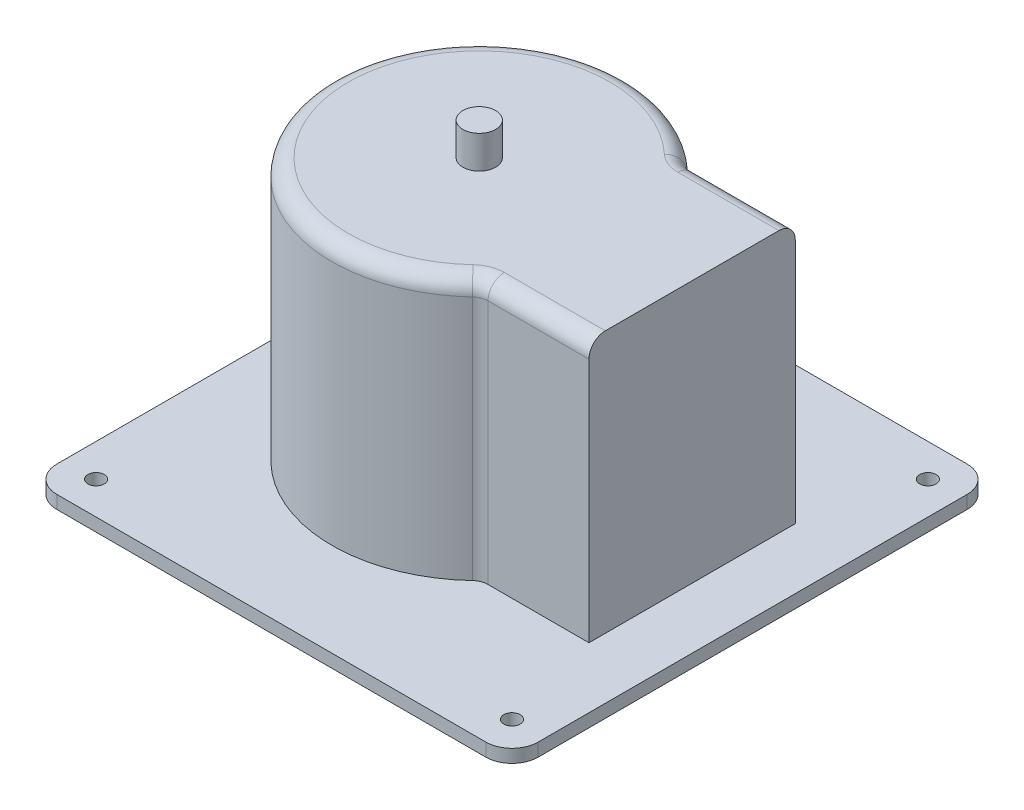
from build123d import *

# Parameters (mm, degrees)
SKETCH1_R           = 45
BOSS_EXTRUDE1_DEPTH = 80
BOSS_EXTRUDE2_REACH = 112
SKETCH2_W           = 63
SKETCH2_H           = 80
FILLET1_R           = 5
SKETCH3_R           = 5
BOSS_EXTRUDE3_DEPTH = 10
SKETCH4_W           = 147
SKETCH4_H           = 147
BOSS_EXTRUDE4_DEPTH = 4
SKETCH5_R           = 2.5
CUT_EXTRUDE1_DEPTH  = 5
FILLET2_R           = 8


with BuildPart() as part:
    # Sketch1 → Boss-Extrude1 (new body)
    with BuildSketch(Plane(origin=(0, 0, 0), x_dir=(1, 0, 0), z_dir=(0, 1, 0))):
        Circle(SKETCH1_R)
    extrude(amount=BOSS_EXTRUDE1_DEPTH)

    # Sketch2 → Boss-Extrude2 (add, up to next)
    with BuildSketch(Plane(origin=(65, 0, 0), x_dir=(0, 0, -1), z_dir=(1, 0, 0)), mode=Mode.PRIVATE) as boss_extrude2_sk1:
        with Locations((0, 40)):
            Rectangle(SKETCH2_W, SKETCH2_H)
    boss_extrude2_tool1 = extrude(boss_extrude2_sk1.sketch, amount=-BOSS_EXTRUDE2_REACH, mode=Mode.PRIVATE) - part.part
    add(boss_extrude2_tool1.solids().sort_by_distance((65, 40, 0))[0])

    # Fillet1
    fillet1_edges = [part.edges().sort_by_distance(p)[0] for p in [
        (-45, 80, 0),
        (32.136427928, 40, -31.5),
        (48.568213964, 80, -31.5),
        (48.568213964, 80, 31.5),
        (32.136427928, 40, 31.5),
    ]]
    fillet(fillet1_edges, radius=FILLET1_R)

    # Sketch3 → Boss-Extrude3 (add)
    with BuildSketch(Plane(origin=(0, 80, 0), x_dir=(1, 0, 0), z_dir=(0, 1, 0))):
        Circle(SKETCH3_R)
    extrude(amount=BOSS_EXTRUDE3_DEPTH)

    # Sketch4 → Boss-Extrude4 (add)
    with BuildSketch(Plane.XZ):
        with Locations((10, 0)):
            Rectangle(SKETCH4_W, SKETCH4_H)
    extrude(amount=BOSS_EXTRUDE4_DEPTH)

    # Sketch5 → Cut-Extrude1 (cut, through all)
    with BuildSketch(Plane(origin=(0, 0, 0), x_dir=(1, 0, 0), z_dir=(0, 1, 0))):
        with Locations((-53.5, 63.5)):
            Circle(SKETCH5_R)
        with Locations((73.5, 63.5)):
            Circle(SKETCH5_R)
        with Locations((-53.5, -63.5)):
            Circle(SKETCH5_R)
        with Locations((73.5, -63.5)):
            Circle(SKETCH5_R)
    extrude(amount=-CUT_EXTRUDE1_DEPTH, mode=Mode.SUBTRACT)

    # Fillet2
    fillet2_edges = [part.edges().sort_by_distance(p)[0] for p in [
        (-63.5, -2, 73.5),
        (-63.5, -2, -73.5),
        (83.5, -2, -73.5),
        (83.5, -2, 73.5),
    ]]
    fillet(fillet2_edges, radius=FILLET2_R)


solid = part.part
